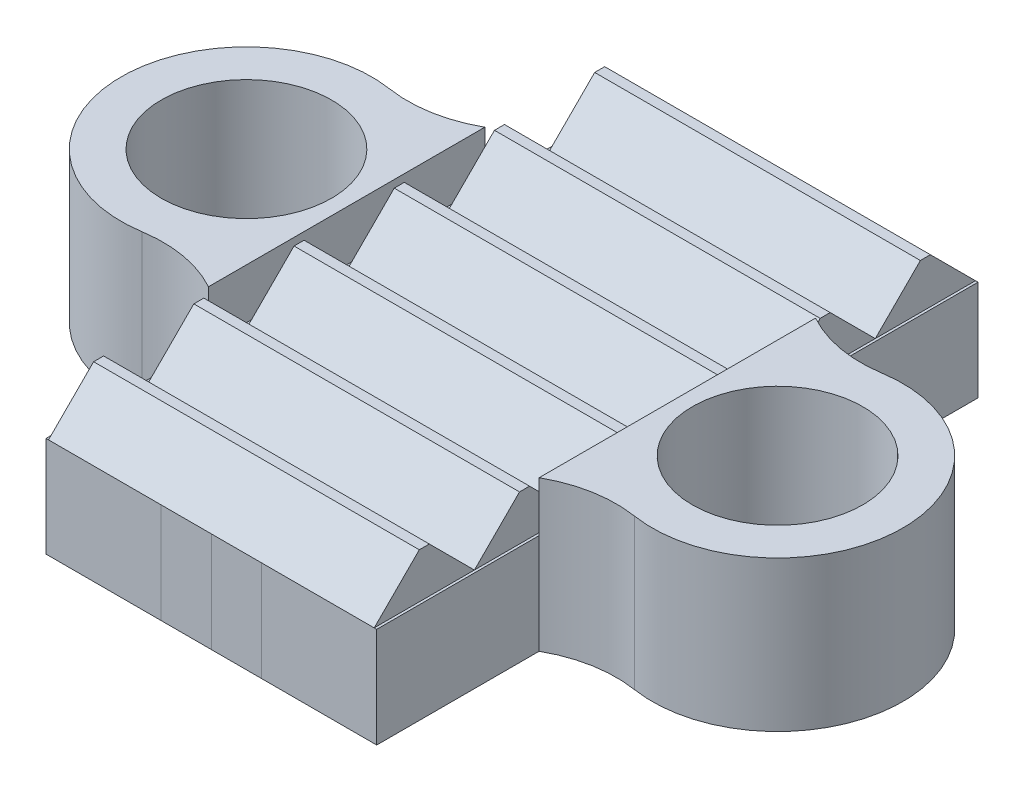
from build123d import *

# Parameters (mm, degrees)
CROQUIS1_R              = 1.7
SALIENTE_EXTRUIR1_DEPTH = 2
SALIENTE_EXTRUIR2_DEPTH = 6.5
MATRIZL1_COUNT          = 6
MATRIZL1_PITCH          = 2
SKETCH1_W               = 2
SKETCH1_H               = 2
CUT_EXTRUDE1_DEPTH      = 0.1
SKETCH1_3_W             = 1
SKETCH1_3_H             = 2
BOSS_EXTRUDE1_DEPTH     = 0.1
SKETCH1_4_W             = 1
SKETCH1_4_H             = 2
BOSS_EXTRUDE2_DEPTH     = 0.1
BOSS_EXTRUDE3_START     = 2
CROQUIS1_4_R            = 1.7
BOSS_EXTRUDE3_DEPTH     = 1


with BuildPart() as part:
    # Croquis1 → Saliente-Extruir1 (new body)
    with BuildSketch(Plane(origin=(0, 0, 0), x_dir=(1, 0, 0), z_dir=(0, 1, 0))):
        Polygon((-3.3, -2.758060528), (-3.3, 2.758060528), (-3.3, 6), (3.3, 6), (3.3, 2.758060528), (3.3, -2.758060528), (3.3, -6), (-3.3, -6), align=None)
        with BuildLine():
            Line((3.3, -2.758060528), (3.3, 2.758060528))
            ThreePointArc((3.3, 2.758060528), (4.081204524, 2.478243977), (4.910964812, 2.469544821))
            ThreePointArc((4.910964812, 2.469544821), (7.8, 0), (4.910964812, -2.469544821))
            ThreePointArc((4.910964812, -2.469544821), (4.081204524, -2.478243977), (3.3, -2.758060528))
        make_face()
        with Locations((5.3, 0)):
            Circle(CROQUIS1_R, mode=Mode.SUBTRACT)
        with BuildLine():
            ThreePointArc((-4.910964812, -2.469544821), (-7.8, 0), (-4.910964812, 2.469544821))
            ThreePointArc((-4.910964812, 2.469544821), (-4.081204524, 2.478243977), (-3.3, 2.758060528))
            Line((-3.3, 2.758060528), (-3.3, -2.758060528))
            ThreePointArc((-3.3, -2.758060528), (-4.081204524, -2.478243977), (-4.910964812, -2.469544821))
        make_face()
        with Locations((-5.3, 0)):
            Circle(CROQUIS1_R, mode=Mode.SUBTRACT)
    extrude(amount=SALIENTE_EXTRUIR1_DEPTH)

    # Croquis4 → Saliente-Extruir2 (add)
    with BuildSketch(Plane(origin=(3.25, 0, 0), x_dir=(0, 0, -1), z_dir=(1, 0, 0))):
        Polygon((-6, 2), (-4, 2), (-4.9, 2.9), (-5.1, 2.9), align=None)
    saliente_extruir2 = extrude(amount=-SALIENTE_EXTRUIR2_DEPTH)

    # MatrizL1: Saliente-Extruir2 ×6
    with Locations(*[(0, 0, -i * MATRIZL1_PITCH) for i in range(1, MATRIZL1_COUNT)]):
        add(saliente_extruir2)

    # Sketch1 → Cut-Extrude1 (cut)
    with BuildSketch(Plane.XY.offset(6)):
        with Locations((0, 1)):
            Rectangle(SKETCH1_W, SKETCH1_H)
    extrude(amount=-CUT_EXTRUDE1_DEPTH, mode=Mode.SUBTRACT)

    # Croquis1_4 → Boss-Extrude3 (add)
    with BuildSketch(Plane(origin=(0, 0, 0), x_dir=(1, 0, 0), z_dir=(0, 1, 0)).offset(BOSS_EXTRUDE3_START)):
        with BuildLine():
            ThreePointArc((-4.910964812, -2.469544821), (-7.8, 0), (-4.910964812, 2.469544821))
            ThreePointArc((-4.910964812, 2.469544821), (-4.081204524, 2.478243977), (-3.3, 2.758060528))
            Line((-3.3, 2.758060528), (-3.3, -2.758060528))
            ThreePointArc((-3.3, -2.758060528), (-4.081204524, -2.478243977), (-4.910964812, -2.469544821))
        make_face()
        with Locations((-5.3, 0)):
            Circle(CROQUIS1_4_R, mode=Mode.SUBTRACT)
        with BuildLine():
            Line((3.3, -2.758060528), (3.3, 2.758060528))
            ThreePointArc((3.3, 2.758060528), (4.081204524, 2.478243977), (4.910964812, 2.469544821))
            ThreePointArc((4.910964812, 2.469544821), (7.8, 0), (4.910964812, -2.469544821))
            ThreePointArc((4.910964812, -2.469544821), (4.081204524, -2.478243977), (3.3, -2.758060528))
        make_face()
        with Locations((5.3, 0)):
            Circle(CROQUIS1_4_R, mode=Mode.SUBTRACT)
    extrude(amount=BOSS_EXTRUDE3_DEPTH)


with BuildPart() as body_2:
    # Sketch1_3 → Boss-Extrude1 (new body)
    with BuildSketch(Plane.XY.offset(6)):
        with Locations((0.5, 1)):
            Rectangle(SKETCH1_3_W, SKETCH1_3_H)
    extrude(amount=-BOSS_EXTRUDE1_DEPTH)


with BuildPart() as body_3:
    # Sketch1_4 → Boss-Extrude2 (new body)
    with BuildSketch(Plane.XY.offset(6)):
        with Locations((-0.5, 1)):
            Rectangle(SKETCH1_4_W, SKETCH1_4_H)
    extrude(amount=-BOSS_EXTRUDE2_DEPTH)


solid = Compound([part.part, body_2.part, body_3.part])
